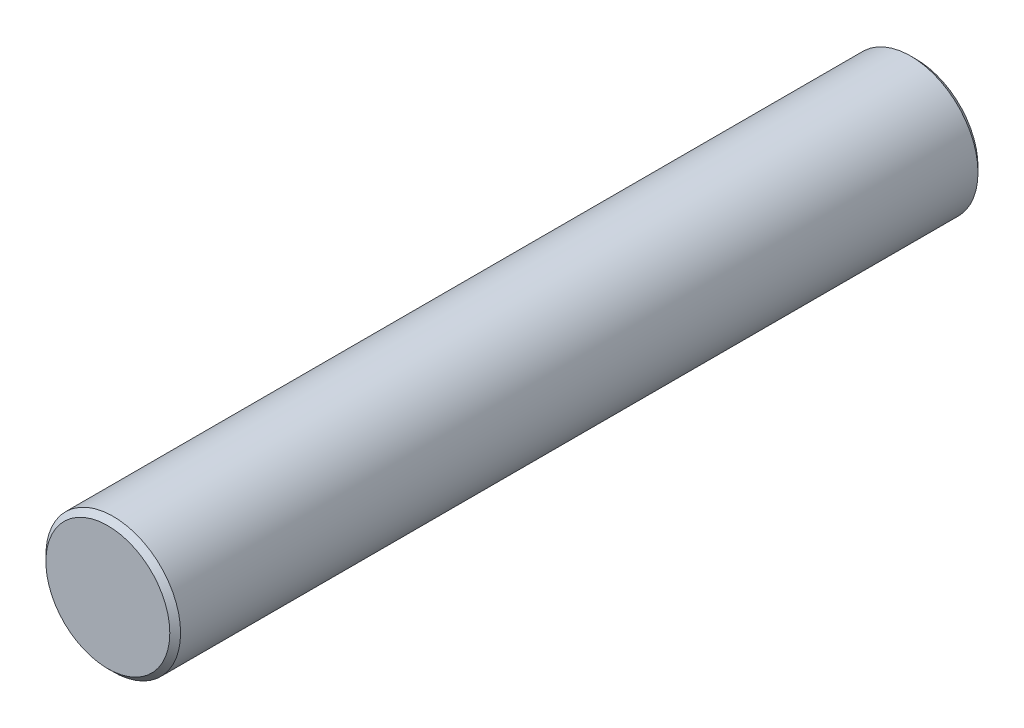
from build123d import *

# Parameters (mm, degrees)
SKETCH2_R           = 2.5
BOSS_EXTRUDE1_DEPTH = 30
CHAMFER1_SIZE       = 0.2


with BuildPart() as part:
    # Sketch2 → Boss-Extrude1 (new body)
    with BuildSketch(Plane.XY):
        Circle(SKETCH2_R)
    extrude(amount=BOSS_EXTRUDE1_DEPTH)

    # Chamfer1
    chamfer1_edges = [part.edges().sort_by_distance(p)[0] for p in [
        (-2.5, 0, 0),
        (-2.5, 0, 30),
    ]]
    chamfer(chamfer1_edges, length=CHAMFER1_SIZE)


solid = part.part
